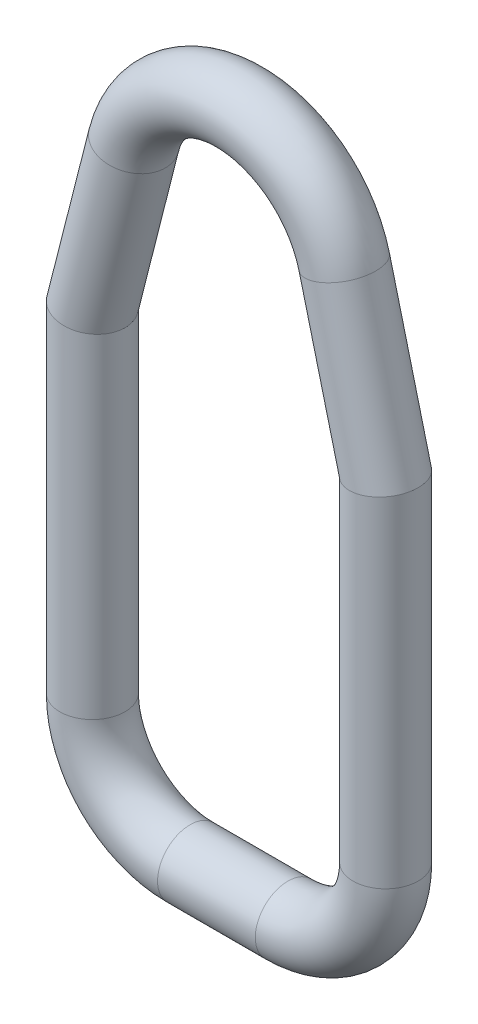
from build123d import *

# Parameters (mm, degrees)
SKETCH2_R = 0.762


with BuildPart() as part:
    # Base-Sweep: sweep along a path in Sketch1
    with BuildLine(Plane.XY) as base_sweep_path:
        Line((-1.143, 0), (1.143, 0))
        ThreePointArc((1.143, 0), (2.759446102, 0.669553898), (3.429, 2.286))
        Line((3.429, 2.286), (3.429, 10.16))
        Line((3.429, 10.16), (2.461534374, 13.961457123))
        ThreePointArc((2.461534374, 13.961457123), (0, 15.875), (-2.461534374, 13.961457123))
        Line((-2.461534374, 13.961457123), (-3.429, 10.16))
        Line((-3.429, 10.16), (-3.429, 2.286))
        ThreePointArc((-3.429, 2.286), (-2.759446102, 0.669553898), (-1.143, 0))
    # Sketch2 → Base-Sweep (sweep)
    with BuildSketch(Plane(origin=(0, 0, 0), x_dir=(0, 0, -1), z_dir=(1, 0, 0))):
        Circle(SKETCH2_R)
    sweep(path=base_sweep_path.line, transition=Transition.RIGHT)


solid = part.part
